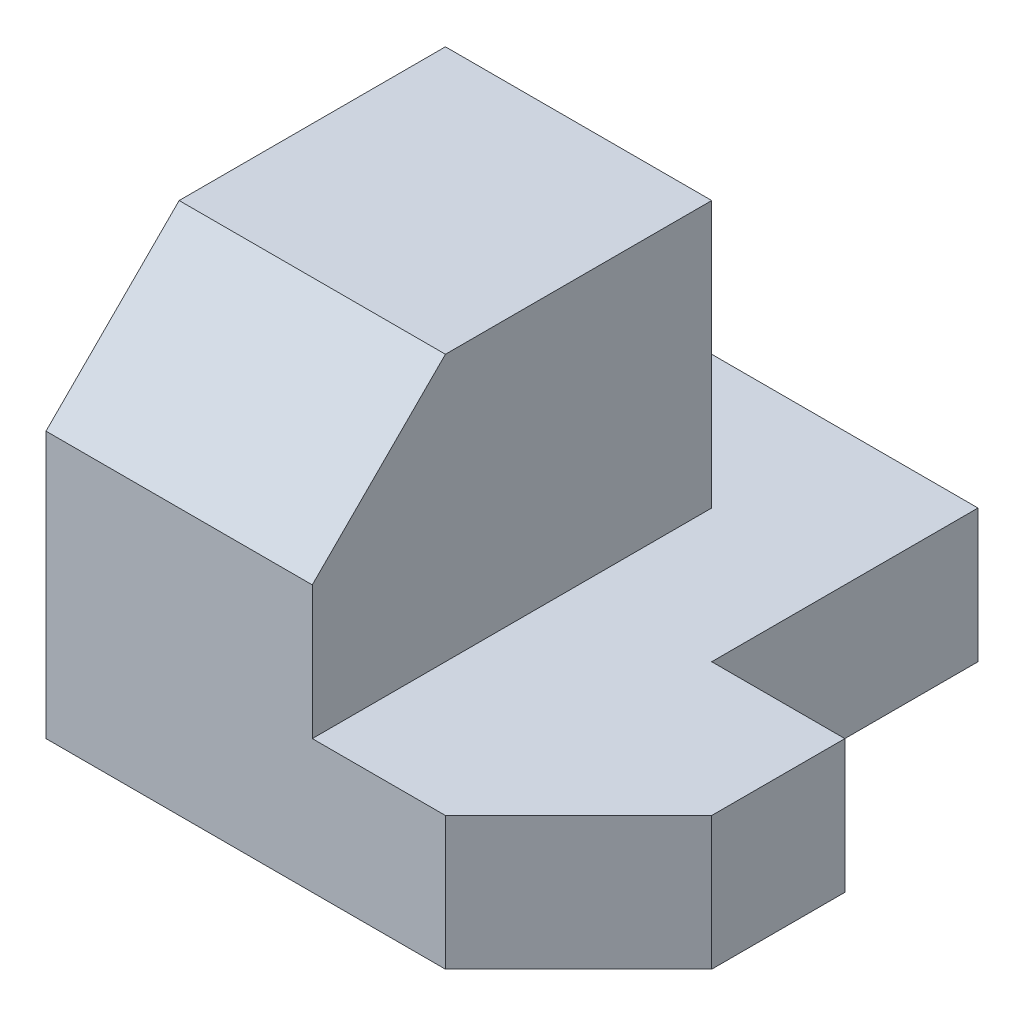
from build123d import *

# Parameters (mm, degrees)
EXTRUDE_1_DEPTH     = 5
SKETCH_1_3_W        = 10
SKETCH_1_3_H        = 15
EXTRUDE_2_DEPTH     = 15
CUT_EXTRUDE_1_DEPTH = 15


with BuildPart() as part:
    # 草圖1 → 填料-伸長1 (new body)
    with BuildSketch(Plane(origin=(0, 0, 0), x_dir=(1, 0, 0), z_dir=(0, 1, 0))):
        Polygon((0, 0), (15, 0), (20, 5), (20, 10), (15, 10), (15, 20), (0, 20), align=None)
    extrude(amount=EXTRUDE_1_DEPTH)

    # 草圖1<3> → 填料-伸長2 (add)
    with BuildSketch(Plane(origin=(0, 0, 0), x_dir=(1, 0, 0), z_dir=(0, 1, 0))):
        with Locations((5, 7.5)):
            Rectangle(SKETCH_1_3_W, SKETCH_1_3_H)
    extrude(amount=EXTRUDE_2_DEPTH)

    # 草圖2 → 除料-伸長1 (cut)
    with BuildSketch(Plane(origin=(10, 0, 0), x_dir=(0, 0, -1), z_dir=(1, 0, 0))):
        Polygon((0, 15), (0, 10), (5, 15), align=None)
    extrude(amount=-CUT_EXTRUDE_1_DEPTH, mode=Mode.SUBTRACT)


solid = part.part
